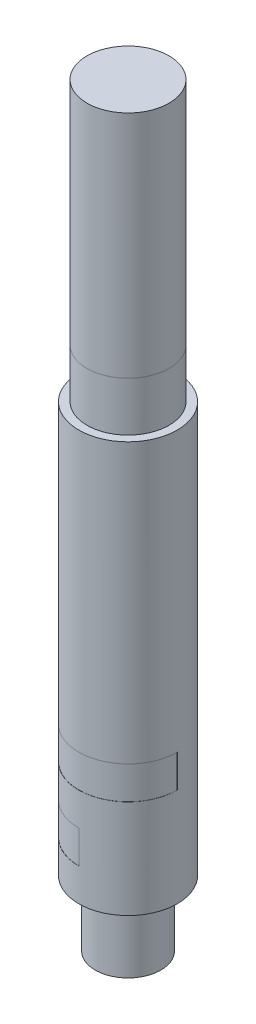
from build123d import *

# Parameters (mm, degrees)
SKETCH1_R           = 7.9375
BOSS_EXTRUDE1_DEPTH = 53.975
SKETCH2_R           = 9.525
BOSS_EXTRUDE2_DEPTH = 79.375
SKETCH3_R           = 6.35
BOSS_EXTRUDE3_DEPTH = 12.7
CUT_EXTRUDE1_DEPTH  = 6.35
CUT_EXTRUDE2_DEPTH  = 6.35


with BuildPart() as part:
    # Sketch1 → Boss-Extrude1 (new body)
    with BuildSketch(Plane(origin=(0, 0, 0), x_dir=(1, 0, 0), z_dir=(0, 1, 0))):
        with Locations(Location((0, 0, 0), (0, 0, 270))):  # turned: the seam where the file's is
            Circle(SKETCH1_R)
    extrude(amount=BOSS_EXTRUDE1_DEPTH)

    # Sketch2 → Boss-Extrude2 (add)
    with BuildSketch(Plane.XZ):
        with Locations(Location((0, 0, 0), (0, 0, 270))):  # turned: the seam where the file's is
            Circle(SKETCH2_R)
    extrude(amount=BOSS_EXTRUDE2_DEPTH)

    # Sketch3 → Boss-Extrude3 (add)
    with BuildSketch(Plane.XZ.offset(79.375)):
        with Locations(Location((0, 0, 0), (0, 0, 270))):  # turned: the seam where the file's is
            Circle(SKETCH3_R)
    extrude(amount=BOSS_EXTRUDE3_DEPTH)

    # Sketch4 → Cut-Extrude1 (cut)
    with BuildSketch(Plane(origin=(0, -73.025, 0), x_dir=(-1, 0, 0), z_dir=(0, -1, 0))):
        with BuildLine():
            Line((0, 9.525), (0, 9.4996))
            ThreePointArc((0, 9.4996), (9.4996, 0), (0, -9.4996))
            Line((0, -9.4996), (0, -9.525))
            ThreePointArc((0, -9.525), (9.525, 0), (0, 9.525))
        make_face()
    extrude(amount=-CUT_EXTRUDE1_DEPTH, mode=Mode.SUBTRACT)

    # Sketch5 → Cut-Extrude2 (cut)
    with BuildSketch(Plane.XZ.offset(60.325)):
        with BuildLine():
            Line((-9.525, 0), (-9.4996, 0))
            ThreePointArc((-9.4996, 0), (0, 9.4996), (9.4996, 0))
            Line((9.4996, 0), (9.525, 0))
            ThreePointArc((9.525, 0), (0, 9.525), (-9.525, 0))
        make_face()
    extrude(amount=-CUT_EXTRUDE2_DEPTH, mode=Mode.SUBTRACT)


solid = part.part
